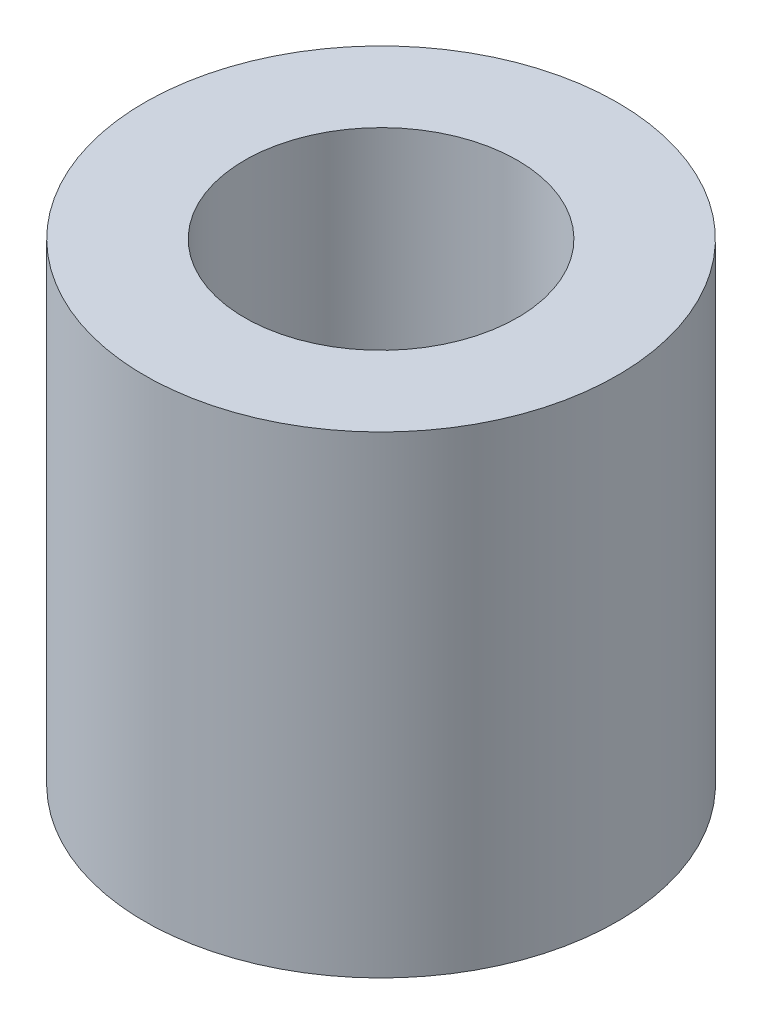
from build123d import *


with BuildPart() as part:
    # Sketch2 → Revolve1 (revolve)
    with BuildSketch(Plane.XY):
        Polygon((3.175, -0.79375), (3.175, -10.31875), (10.31875, -10.31875), (10.31875, 10.31875), (5.953125, 10.31875), (5.953125, -0.79375), align=None)
    revolve(axis=Axis((0, 0, 0), (0, 1, 0)))


solid = part.part
